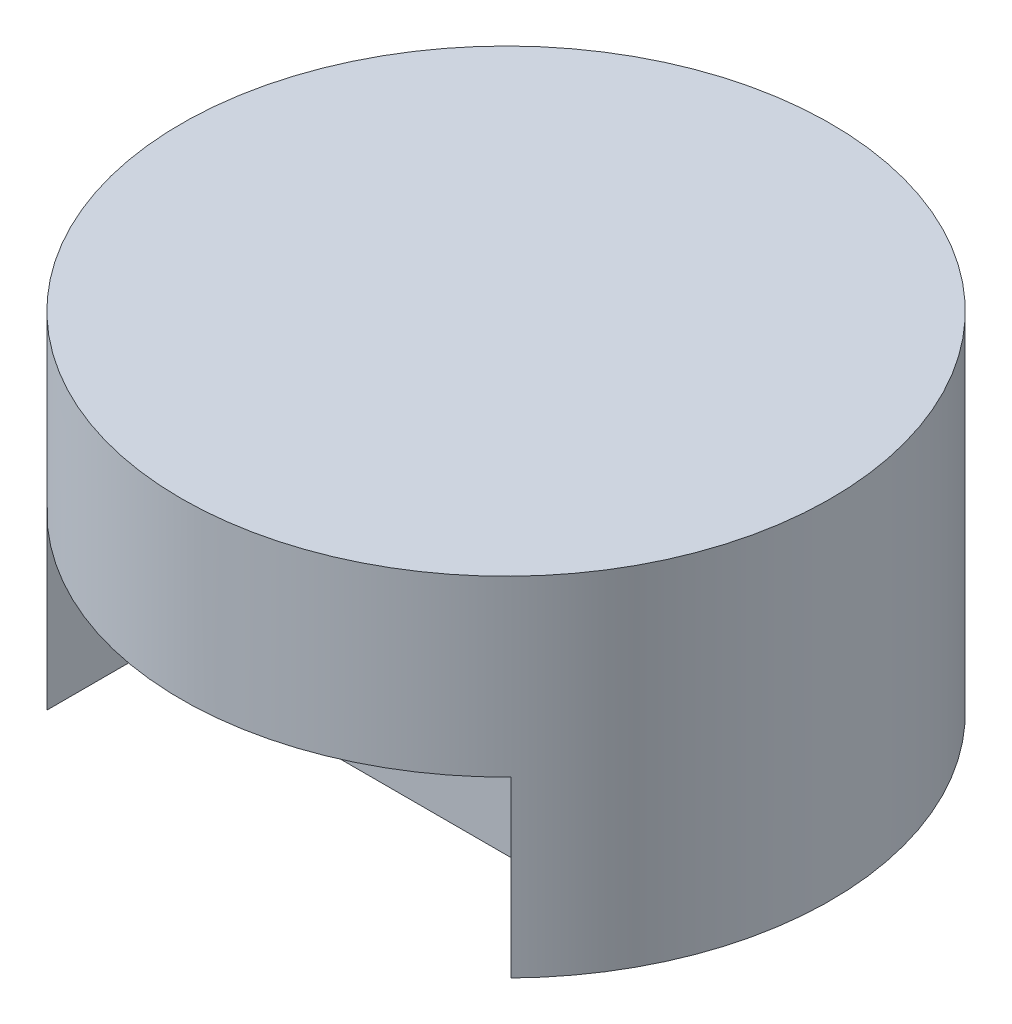
from build123d import *

# Parameters (mm, degrees)
SKETCH1_R           = 140
BOSS_EXTRUDE1_DEPTH = 150
CUT_EXTRUDE1_DEPTH  = 75


with BuildPart() as part:
    # Sketch1 → Boss-Extrude1 (new body)
    with BuildSketch(Plane(origin=(0, 0, 0), x_dir=(1, 0, 0), z_dir=(0, 1, 0))):
        Circle(SKETCH1_R)
    extrude(amount=BOSS_EXTRUDE1_DEPTH)

    # Sketch2 → Cut-Extrude1 (cut)
    with BuildSketch(Plane.XZ):
        with BuildLine():
            Line((-100, 97.979589711), (-100, 52.979589711))
            Line((-100, 52.979589711), (100, 52.979589711))
            Line((100, 52.979589711), (100, 97.979589711))
            ThreePointArc((100, 97.979589711), (0, 140), (-100, 97.979589711))
        make_face()
    extrude(amount=-CUT_EXTRUDE1_DEPTH, mode=Mode.SUBTRACT)


solid = part.part
